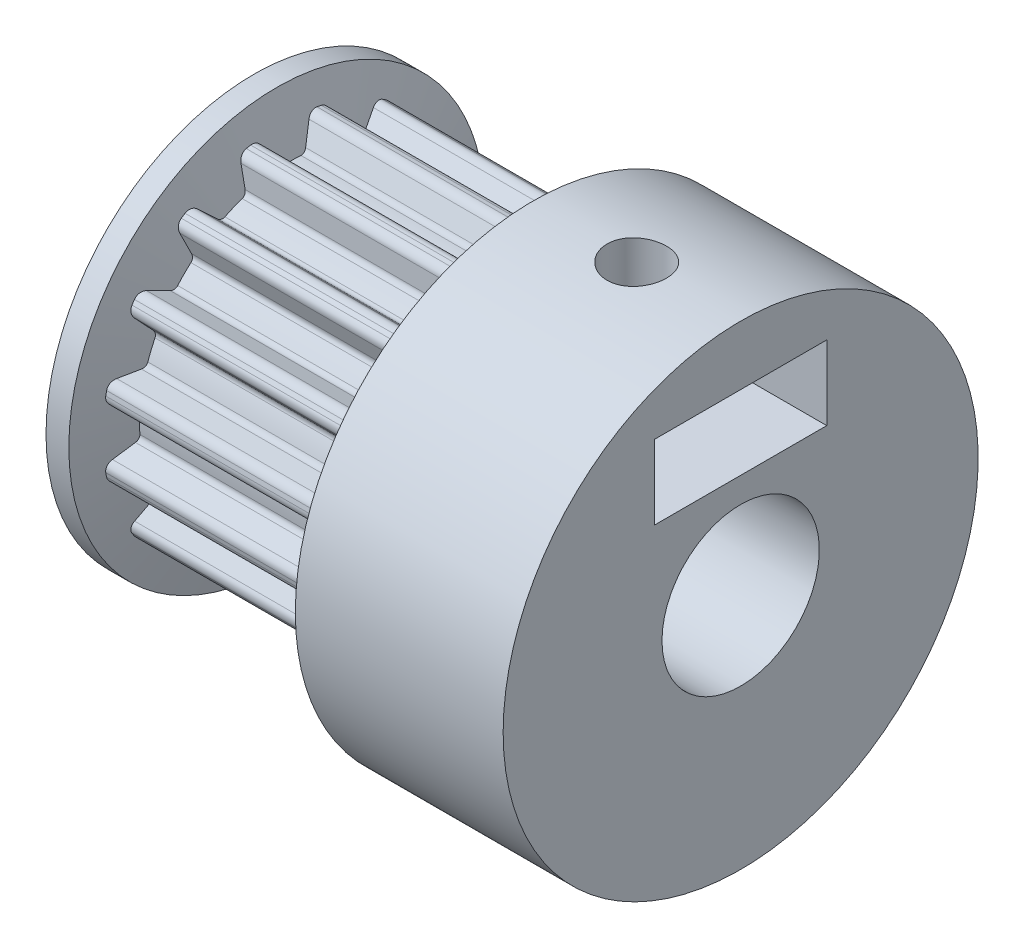
from build123d import *

# Parameters (mm, degrees)
SKETCH2_W          = 9
SKETCH2_H          = 6.1
COG_DEPTH          = 10
PATTERN_COG_COUNT  = 16
SKETCH3_W          = 7
SKETCH3_H          = 8
SKETCH8_W          = 16
SKETCH8_H          = 2.65
SKETCH15_W         = 1
SKETCH15_H         = 197.35
CUT_EXTRUDE1_DEPTH = 2.5


with BuildPart() as part:
    # Sketch2 → Body (revolve)
    with BuildSketch(Plane.XY):
        with Locations((4.5, 3.05)):
            Rectangle(SKETCH2_W, SKETCH2_H)
    revolve(axis=Axis((0, 0, 0), (1, 0, 0)))

    # Sketch6 → Cog (cut, through all)
    with BuildSketch(Plane(origin=(0, 0, 0), x_dir=(0, 0, -1), z_dir=(1, 0, 0))):
        with BuildLine():
            Line((0.789835397, 5.82877936), (0.508392514, 5.225223151))
            ThreePointArc((0.508392514, 5.225223151), (0.429351309, 5.137842761), (0.314832372, 5.1101253))
            ThreePointArc((0.314832372, 5.1101253), (0, 5.11981445), (-0.314832372, 5.1101253))
            ThreePointArc((-0.314832372, 5.1101253), (-0.429351309, 5.137842761), (-0.508392514, 5.225223151))
            Line((-0.508392514, 5.225223151), (-0.789835397, 5.82877936))
            ThreePointArc((-0.789835397, 5.82877936), (-0.924476923, 5.968756351), (-1.116644684, 5.996924599))
            ThreePointArc((-1.116644684, 5.996924599), (0, 6.1), (1.116644684, 5.996924599))
            ThreePointArc((1.116644684, 5.996924599), (0.924476923, 5.968756351), (0.789835397, 5.82877936))
        make_face()
    cog = extrude(amount=COG_DEPTH, mode=Mode.SUBTRACT)

    # Pattern-Cog: Cog ×16 about axis
    pattern_cog_axis = Axis((0, 0, 0), (1, 0, 0))
    for i in range(1, PATTERN_COG_COUNT):
        add(cog.rotate(pattern_cog_axis, i * 360 / PATTERN_COG_COUNT), mode=Mode.SUBTRACT)

    # Sketch3 → Hub (revolve)
    with BuildSketch(Plane.XY):
        with Locations((12.5, 4)):
            Rectangle(SKETCH3_W, SKETCH3_H)
    revolve(axis=Axis((0, 0, 0), (1, 0, 0)))

    # Sketch8 → Hole-Shaft (revolve, cut)
    with BuildSketch(Plane.XY):
        with Locations((8, -1.325)):
            Rectangle(SKETCH8_W, SKETCH8_H)
    revolve(axis=Axis((0, 0, 0), (1, 0, 0)), mode=Mode.SUBTRACT)

    # Sketch15 → Stop-Screw (revolve, cut)
    with BuildSketch(Plane.XY):
        with Locations((13, 98.675)):
            Rectangle(SKETCH15_W, SKETCH15_H)
    revolve(axis=Axis((12.5, 197.35, 0), (0, -1, 0)), mode=Mode.SUBTRACT)

    # Sketch16 → Flange-Left (revolve)
    with BuildSketch(Plane.XY):
        Polygon((0, 2.542315139), (-0.39810301, 2.542315139), (-0.39810301, 7), (0.370293839, 7), (1.10189699, 4.269619869), (1.10189699, 2.542315139), align=None)
    revolve(axis=Axis((0, 0, 0), (1, 0, 0)))

    # Sketch18 → Cut-Extrude1 (cut)
    with BuildSketch(Plane(origin=(0, 3.5, 0), x_dir=(-1, 0, 0), z_dir=(0, 1, 0))):
        Polygon((-16.41744749, 2.9), (-16.41744749, -2.9), (-10.825684219, -2.9), (-9.151368439, 0), (-10.825684219, 2.9), align=None)
    extrude(amount=CUT_EXTRUDE1_DEPTH, mode=Mode.SUBTRACT)


solid = part.part
